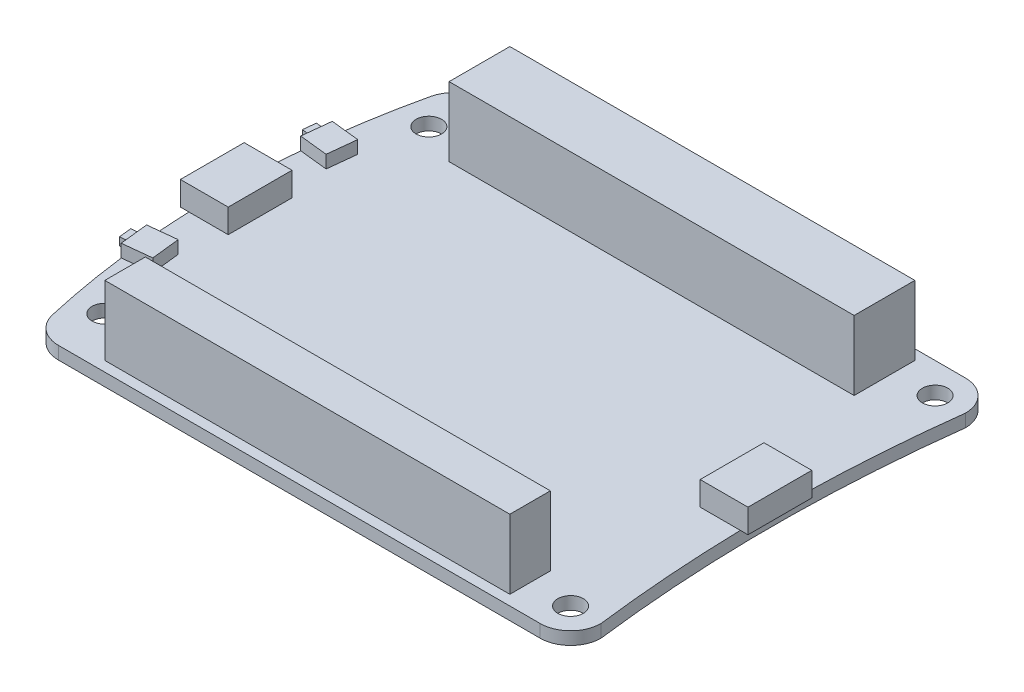
from build123d import *

# Parameters (mm, degrees)
SKETCH1_R           = 1.6
BOSS_EXTRUDE1_DEPTH = 1.6
SKETCH2_W           = 6
SKETCH2_H           = 8
BOSS_EXTRUDE2_DEPTH = 3
BOSS_EXTRUDE3_DEPTH = 1.6
SKETCH4_W           = 1.6
SKETCH4_H           = 1
BOSS_EXTRUDE4_DEPTH = 1
SKETCH5_W           = 1.6
SKETCH5_H           = 1
BOSS_EXTRUDE5_DEPTH = 1
SKETCH6_W           = 50.8
SKETCH6_H           = 5.08
SKETCH6_H_2         = 7.62
BOSS_EXTRUDE6_DEPTH = 8.7


with BuildPart() as part:
    # Sketch1 → Boss-Extrude1 (new body)
    with BuildSketch(Plane(origin=(0, 0, 0), x_dir=(1, 0, 0), z_dir=(0, 1, 0))):
        with BuildLine():
            Line((30.48, 26.67), (-29.941284627, 26.67))
            ThreePointArc((-29.941284627, 26.67), (-32.31004746, 25.841357037), (-33.645726791, 23.716822443))
            ThreePointArc((-33.645726791, 23.716822443), (-36.322, 0), (-33.645726791, -23.716822443))
            ThreePointArc((-33.645726791, -23.716822443), (-32.31004746, -25.841357037), (-29.941284627, -26.67))
            Line((-29.941284627, -26.67), (30.48, -26.67))
            ThreePointArc((30.48, -26.67), (33.174076836, -25.554076836), (34.29, -22.86))
            ThreePointArc((34.29, -22.86), (32.868, 0), (34.29, 22.86))
            ThreePointArc((34.29, 22.86), (33.174076836, 25.554076836), (30.48, 26.67))
        make_face()
        with Locations((30.48, 22.86)):
            Circle(SKETCH1_R, mode=Mode.SUBTRACT)
        with Locations((-30.48, 20.32)):
            Circle(SKETCH1_R, mode=Mode.SUBTRACT)
        with Locations((30.48, -22.86)):
            Circle(SKETCH1_R, mode=Mode.SUBTRACT)
        with Locations((-30.48, -20.32)):
            Circle(SKETCH1_R, mode=Mode.SUBTRACT)
    extrude(amount=BOSS_EXTRUDE1_DEPTH)

    # Sketch2 → Boss-Extrude2 (add)
    with BuildSketch(Plane(origin=(0, 1.6, 0), x_dir=(1, 0, 0), z_dir=(0, 1, 0))):
        with Locations((-34.322, 0)):
            Rectangle(SKETCH2_W, SKETCH2_H)
        with Locations((30.868, 0)):
            Rectangle(SKETCH2_W, SKETCH2_H)
    extrude(amount=BOSS_EXTRUDE2_DEPTH)

    # Sketch3 → Boss-Extrude3 (add)
    with BuildSketch(Plane(origin=(0, 1.6, 0), x_dir=(1, 0, 0), z_dir=(0, 1, 0))):
        Polygon((-35.510618925, 13.239552311), (-31.931514302, 12.85224094), (-32.318825673, 9.273136317), (-35.897930296, 9.660447689), align=None)
        Polygon((-31.931514302, -12.85224094), (-32.318825673, -9.273136317), (-35.897930296, -9.660447689), (-35.510618925, -13.239552311), align=None)
    extrude(amount=BOSS_EXTRUDE3_DEPTH)

    # Sketch4 → Boss-Extrude4 (add)
    with BuildSketch(Plane(origin=(-36.515718124, 0, 3.951533791), x_dir=(0.107586492, 0, 0.994195729), z_dir=(-0.994195729, 0, 0.107586492))):
        with Locations((7.542243437, 2.4)):
            Rectangle(SKETCH4_W, SKETCH4_H)
    extrude(amount=BOSS_EXTRUDE4_DEPTH)

    # Sketch5 → Boss-Extrude5 (add)
    with BuildSketch(Plane(origin=(-36.515718124, 0, -3.951533791), x_dir=(-0.107586492, 0, 0.994195729), z_dir=(-0.994195729, 0, -0.107586492))):
        with Locations((-7.542243437, 2.4)):
            Rectangle(SKETCH5_W, SKETCH5_H)
    extrude(amount=BOSS_EXTRUDE5_DEPTH)

    # Sketch6 → Boss-Extrude6 (add)
    with BuildSketch(Plane(origin=(0, 1.6, 0), x_dir=(1, 0, 0), z_dir=(0, 1, 0))):
        with Locations((0, -22.86)):
            Rectangle(SKETCH6_W, SKETCH6_H)
        with Locations((0, 21.59)):
            Rectangle(SKETCH6_W, SKETCH6_H_2)
    extrude(amount=BOSS_EXTRUDE6_DEPTH)


solid = part.part
